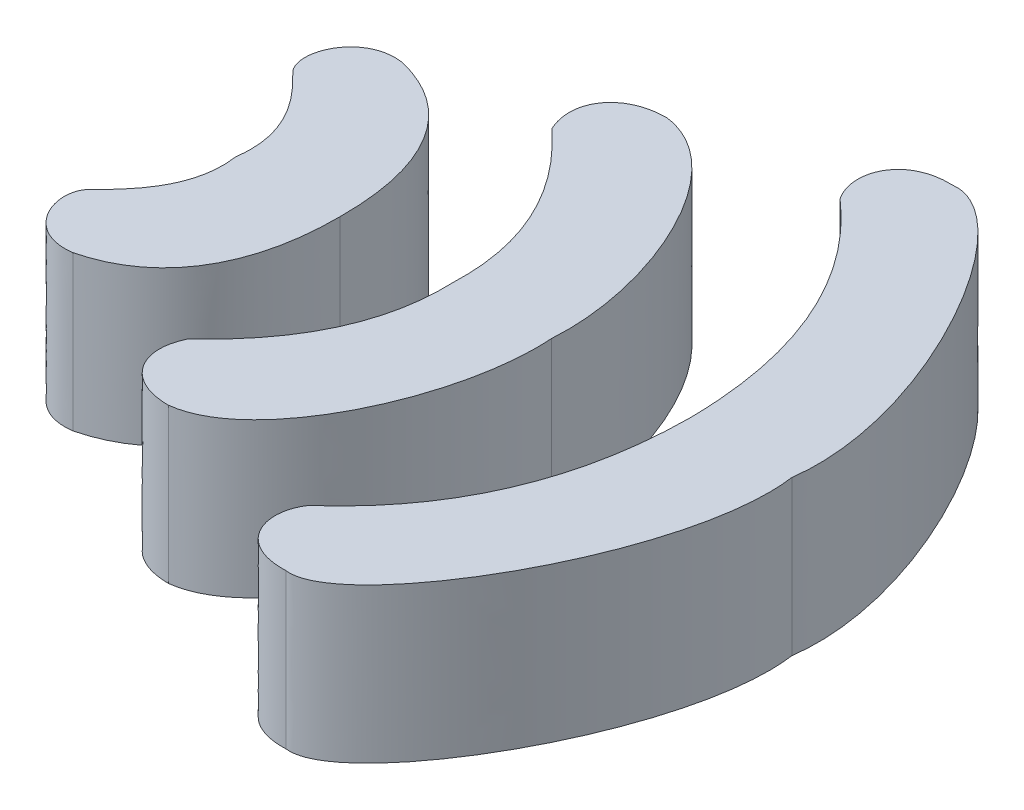
from build123d import *

# Parameters (mm, degrees)
BOSS_EXTRUDE1_DEPTH   = 2
BOSS_EXTRUDE1_2_DEPTH = 2
BOSS_EXTRUDE1_3_DEPTH = 2


with BuildPart() as part:
    # Sketch1 → Boss-Extrude1 (new body)
    with BuildSketch(Plane(origin=(0, 0, 0), x_dir=(1, 0, 0), z_dir=(0, 1, 0))):
        with BuildLine():
            add(Edge.make_bspline(
                [(0.964073923, 6.376306589), (1.338175084, 6.022820676), (1.629590041, 5.613727117), (1.54993416, 5.055796213)],
                knots=[0, 0, 0, 0, 1, 1, 1, 1], degree=3))
            add(Edge.make_bspline(
                [(0.964073923, 3.735285838), (1.338175084, 4.08877175), (1.629590041, 4.497865309), (1.54993416, 5.055796213)],
                knots=[0, 0, 0, 0, 1, 1, 1, 1], degree=3))
            add(Edge.make_bspline(
                [(0.964073923, 3.735285838), (0.739819165, 3.482037926), (0.997231784, 2.838444064), (1.571095534, 2.922053352)],
                knots=[0, 0, 0, 0, 1, 1, 1, 1], degree=3))
            add(Edge.make_bspline(
                [(1.571095534, 2.922053352), (2.505999389, 3.153879104), (2.904284217, 3.992159872), (2.896683391, 5.055796213)],
                knots=[0, 0, 0, 0, 1, 1, 1, 1], degree=3))
            add(Edge.make_bspline(
                [(1.571095534, 7.189539075), (2.505999389, 6.957713322), (2.904284217, 6.119432554), (2.896683391, 5.055796213)],
                knots=[0, 0, 0, 0, 1, 1, 1, 1], degree=3))
            add(Edge.make_bspline(
                [(0.964073923, 6.376306589), (0.739819165, 6.6295545), (0.997231784, 7.273148363), (1.571095534, 7.189539075)],
                knots=[0, 0, 0, 0, 1, 1, 1, 1], degree=3))
        make_face()
    extrude(amount=BOSS_EXTRUDE1_DEPTH)


with BuildPart() as body_2:
    # Sketch1 → Boss-Extrude1 2 (new body)
    with BuildSketch(Plane(origin=(0, 0, 0), x_dir=(1, 0, 0), z_dir=(0, 1, 0))):
        with BuildLine():
            add(Edge.make_bspline(
                [(4.367307585, 5.055796213), (4.419843992, 6.37031157), (3.285044149, 7.410340663)],
                knots=[0, 0, 0, 1, 1, 1], degree=2))
            add(Edge.make_bspline(
                [(3.285044149, 7.410340663), (3.068332479, 7.856898043), (3.348088621, 8.282455859), (3.899727751, 8.282455859)],
                knots=[0, 0, 0, 0, 1, 1, 1, 1], degree=3))
            add(Edge.make_bspline(
                [(3.899727751, 8.282455859), (4.891364486, 8.170814637), (5.725389356, 6.317773961), (5.633450732, 5.055796213)],
                knots=[0, 0, 0, 0, 1, 1, 1, 1], degree=3))
            add(Edge.make_bspline(
                [(3.899727751, 1.829136567), (4.891364486, 1.940777789), (5.725389356, 3.793818465), (5.633450732, 5.055796213)],
                knots=[0, 0, 0, 0, 1, 1, 1, 1], degree=3))
            add(Edge.make_bspline(
                [(3.285044149, 2.701251763), (3.068332479, 2.254694383), (3.348088621, 1.829136567), (3.899727751, 1.829136567)],
                knots=[0, 0, 0, 0, 1, 1, 1, 1], degree=3))
            add(Edge.make_bspline(
                [(4.367307585, 5.055796213), (4.419843992, 3.741280856), (3.285044149, 2.701251763)],
                knots=[0, 0, 0, 1, 1, 1], degree=2))
        make_face()
    extrude(amount=BOSS_EXTRUDE1_2_DEPTH)


with BuildPart() as body_3:
    # Sketch1 → Boss-Extrude1 3 (new body)
    with BuildSketch(Plane(origin=(0, 0, 0), x_dir=(1, 0, 0), z_dir=(0, 1, 0))):
        with BuildLine():
            add(Edge.make_bspline(
                [(7.421260062, 5.055796213), (7.410575575, 6.399058377), (6.967575118, 7.591580787), (5.936943679, 8.493377715)],
                knots=[0, 0, 0, 0, 1, 1, 1, 1], degree=3))
            add(Edge.make_bspline(
                [(5.936943679, 8.493377715), (5.688376024, 8.853549053), (5.871426312, 9.40411075), (6.520049958, 9.377264355)],
                knots=[0, 0, 0, 0, 1, 1, 1, 1], degree=3))
            add(Edge.make_bspline(
                [(6.520049958, 9.377264355), (7.33799489, 9.482259589), (8.974704126, 6.65572482), (8.749327352, 5.055796213)],
                knots=[0, 0, 0, 0, 1, 1, 1, 1], degree=3))
            add(Edge.make_bspline(
                [(6.520049958, 0.734328071), (7.33799489, 0.629332837), (8.974704126, 3.455867606), (8.749327352, 5.055796213)],
                knots=[0, 0, 0, 0, 1, 1, 1, 1], degree=3))
            add(Edge.make_bspline(
                [(5.936943679, 1.618214711), (5.688376024, 1.258043374), (5.871426312, 0.707481677), (6.520049958, 0.734328071)],
                knots=[0, 0, 0, 0, 1, 1, 1, 1], degree=3))
            add(Edge.make_bspline(
                [(7.421260062, 5.055796213), (7.410575575, 3.712534049), (6.967575118, 2.520011639), (5.936943679, 1.618214711)],
                knots=[0, 0, 0, 0, 1, 1, 1, 1], degree=3))
        make_face()
    extrude(amount=BOSS_EXTRUDE1_3_DEPTH)


solid = Compound([part.part, body_2.part, body_3.part])
